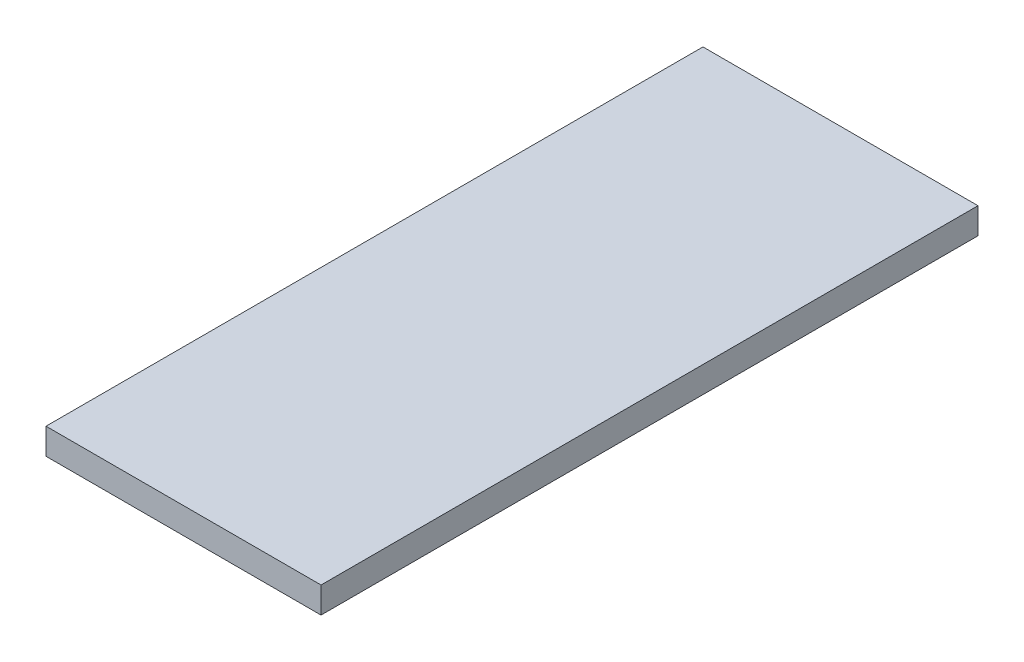
from build123d import *

# Parameters (mm, degrees)
SKETCH1_W           = 50.24
SKETCH1_H           = 120
BOSS_EXTRUDE1_DEPTH = 4.7625


with BuildPart() as part:
    # Sketch1 → Boss-Extrude1 (new body)
    with BuildSketch(Plane(origin=(0, 0, 0), x_dir=(1, 0, 0), z_dir=(0, 1, 0))):
        with Locations((25.12, 60)):
            Rectangle(SKETCH1_W, SKETCH1_H)
    extrude(amount=BOSS_EXTRUDE1_DEPTH)


solid = part.part
